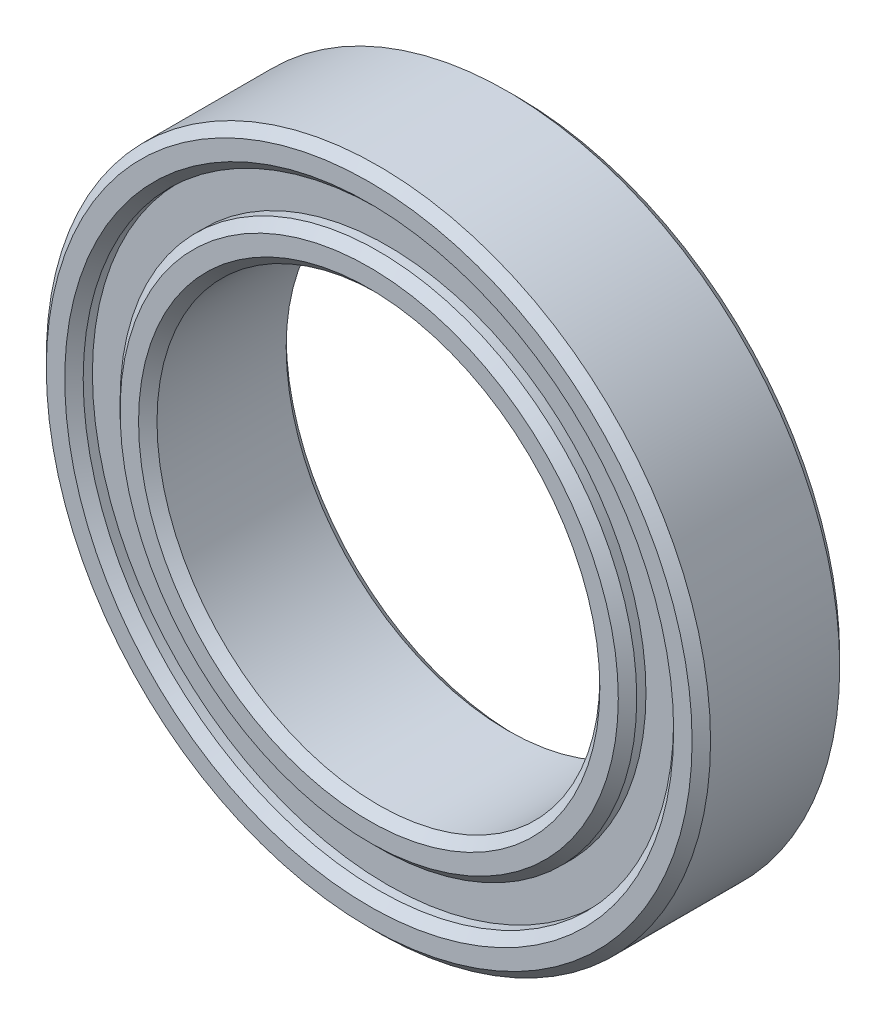
from build123d import *

# Parameters (mm, degrees)
SKETCH2_R           = 9
SKETCH2_R_2         = 6
BOSS_EXTRUDE1_DEPTH = 4
CHAMFER2_SIZE       = 0.25
SKETCH3_R           = 8
SKETCH3_R_2         = 7
CUT_EXTRUDE2_DEPTH  = 0.5
SKETCH4_R           = 8
SKETCH4_R_2         = 7
CUT_EXTRUDE3_DEPTH  = 0.5
CHAMFER3_SIZE       = 0.25


with BuildPart() as part:
    # Sketch2 → Boss-Extrude1 (new body)
    with BuildSketch(Plane.XY):
        Circle(SKETCH2_R)
        Circle(SKETCH2_R_2, mode=Mode.SUBTRACT)
    extrude(amount=BOSS_EXTRUDE1_DEPTH)

    # Chamfer2
    chamfer2_edges = [part.edges().sort_by_distance(p)[0] for p in [
        (-9, 0, 0),
        (-9, 0, 4),
        (-6, 0, 0),
        (-6, 0, 4),
    ]]
    chamfer(chamfer2_edges, length=CHAMFER2_SIZE)

    # Sketch3 → Cut-Extrude2 (cut)
    with BuildSketch(Plane(origin=(0, 0, 0), x_dir=(-1, 0, 0), z_dir=(0, 0, -1))):
        Circle(SKETCH3_R)
        Circle(SKETCH3_R_2, mode=Mode.SUBTRACT)
    extrude(amount=-CUT_EXTRUDE2_DEPTH, mode=Mode.SUBTRACT)

    # Sketch4 → Cut-Extrude3 (cut)
    with BuildSketch(Plane.XY.offset(4)):
        Circle(SKETCH4_R)
        Circle(SKETCH4_R_2, mode=Mode.SUBTRACT)
    extrude(amount=-CUT_EXTRUDE3_DEPTH, mode=Mode.SUBTRACT)

    # Chamfer3
    chamfer3_edges = [part.edges().sort_by_distance(p)[0] for p in [
        (8, 0, 0),
        (7, 0, 0),
        (-8, 0, 4),
        (-7, 0, 4),
    ]]
    chamfer(chamfer3_edges, length=CHAMFER3_SIZE)


solid = part.part
